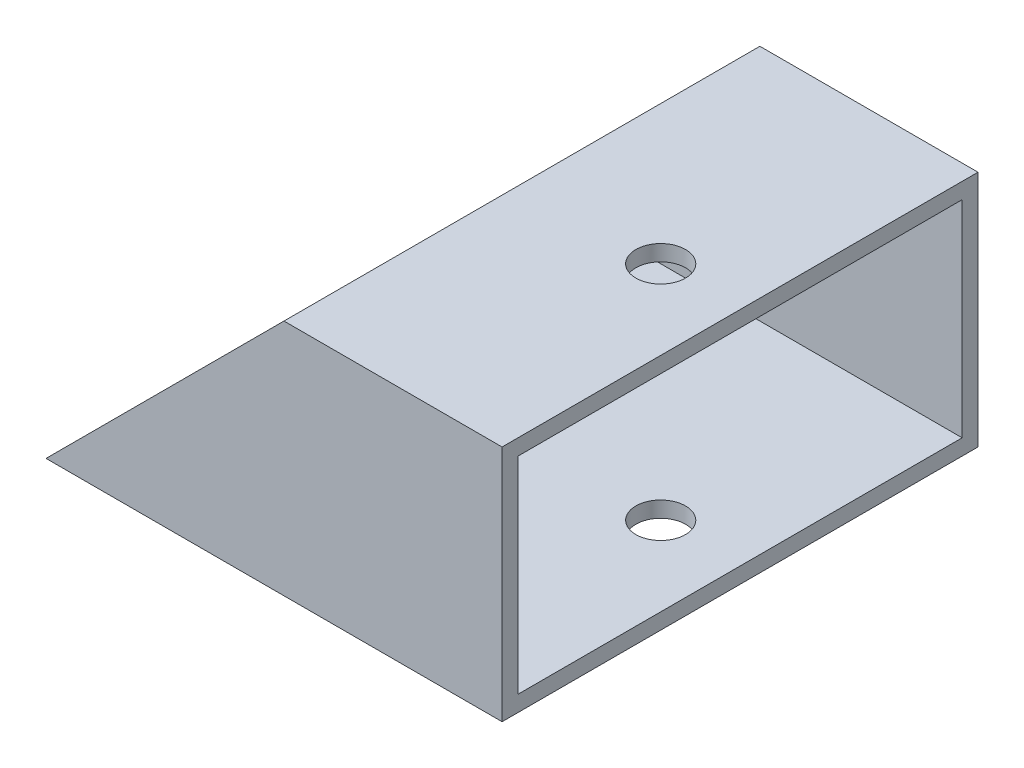
from build123d import *

# Parameters (mm, degrees)
SKETCH1_W           = 76.2
SKETCH1_H           = 38.1
SKETCH1_W_2         = 71.12
SKETCH1_H_2         = 33.02
EXTRUDE_THIN1_DEPTH = 101.6
SKETCH7_R           = 3.9751
CUT_EXTRUDE6_DEPTH  = 39.1
SKETCH10_W          = 76.2
SKETCH10_H          = 38.1
CUT_EXTRUDE9_DEPTH  = 28.575
CUT_EXTRUDE10_DEPTH = 77.2
SKETCH9_R           = 1.5875
CUT_EXTRUDE11_DEPTH = 3.54


with BuildPart() as part:
    # Sketch1 → Extrude-Thin1 (new body)
    with BuildSketch(Plane(origin=(0, 0, 0), x_dir=(0, 0, -1), z_dir=(1, 0, 0))):
        Rectangle(SKETCH1_W, SKETCH1_H)
        Rectangle(SKETCH1_W_2, SKETCH1_H_2, mode=Mode.SUBTRACT)
    extrude(amount=EXTRUDE_THIN1_DEPTH)

    # Sketch7 → Cut-Extrude6 (cut, through all)
    with BuildSketch(Plane(origin=(0, 19.05, 0), x_dir=(1, 0, 0), z_dir=(0, 1, 0))):
        with Locations((88.9, 0)):
            Circle(SKETCH7_R)
    extrude(amount=-CUT_EXTRUDE6_DEPTH, mode=Mode.SUBTRACT)

    # Sketch10 → Cut-Extrude9 (cut)
    with BuildSketch(Plane.ZY):
        Rectangle(SKETCH10_W, SKETCH10_H)
    extrude(amount=-CUT_EXTRUDE9_DEPTH, mode=Mode.SUBTRACT)

    # Sketch11 → Cut-Extrude10 (cut, through all)
    with BuildSketch(Plane(origin=(0, 0, -38.1), x_dir=(-1, 0, 0), z_dir=(0, 0, -1))):
        Polygon((-28.575, -19.05), (-66.675, 19.05), (-28.575, 19.05), align=None)
    extrude(amount=-CUT_EXTRUDE10_DEPTH, mode=Mode.SUBTRACT)

    # Sketch9 → Cut-Extrude11 (cut, through all)
    with BuildSketch(Plane(origin=(0, -16.51, 0), x_dir=(1, 0, 0), z_dir=(0, 1, 0))):
        with Locations((41.275, 0)):
            Circle(SKETCH9_R)
        with Locations((41.275, -25.4)):
            Circle(SKETCH9_R)
        with Locations((41.275, 25.4)):
            Circle(SKETCH9_R)
    extrude(amount=-CUT_EXTRUDE11_DEPTH, mode=Mode.SUBTRACT)


solid = part.part
